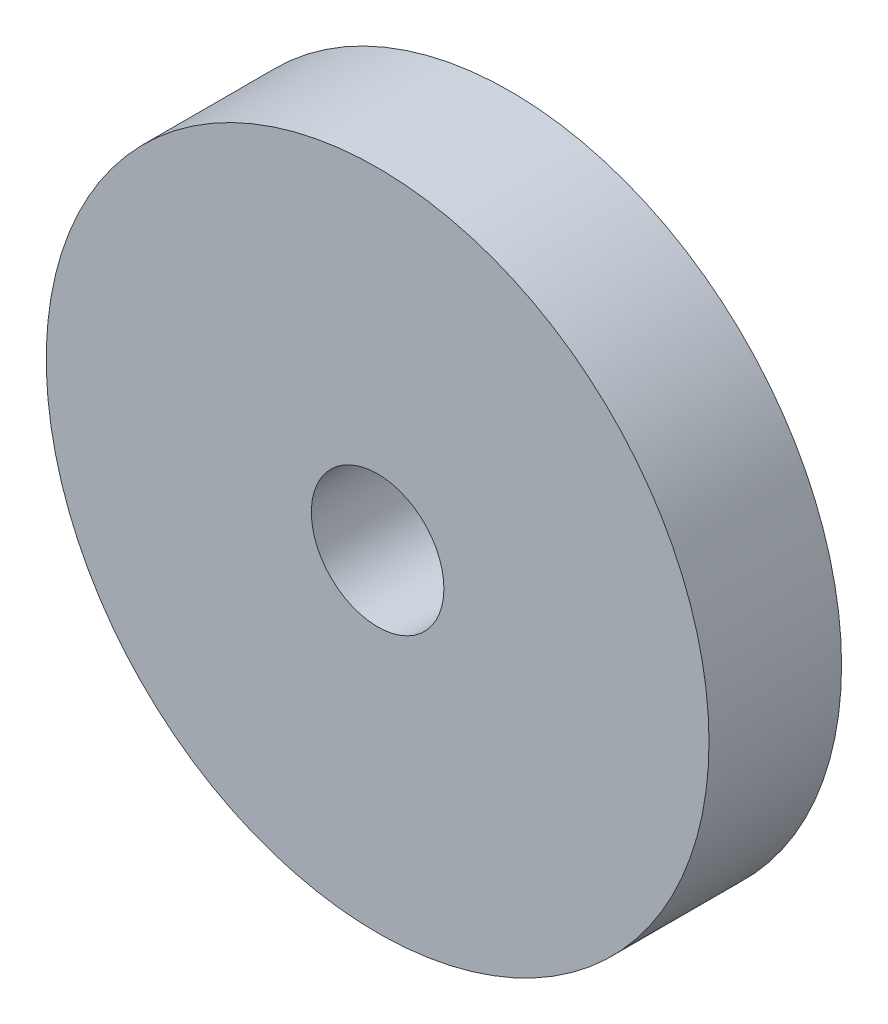
from build123d import *

# Parameters (mm, degrees)
SKETCH1_R           = 5
SKETCH1_R_2         = 1
BOSS_EXTRUDE1_DEPTH = 2


with BuildPart() as part:
    # Sketch1 → Boss-Extrude1 (new body)
    with BuildSketch(Plane.XY):
        Circle(SKETCH1_R)
        Circle(SKETCH1_R_2, mode=Mode.SUBTRACT)
    extrude(amount=BOSS_EXTRUDE1_DEPTH)


solid = part.part
